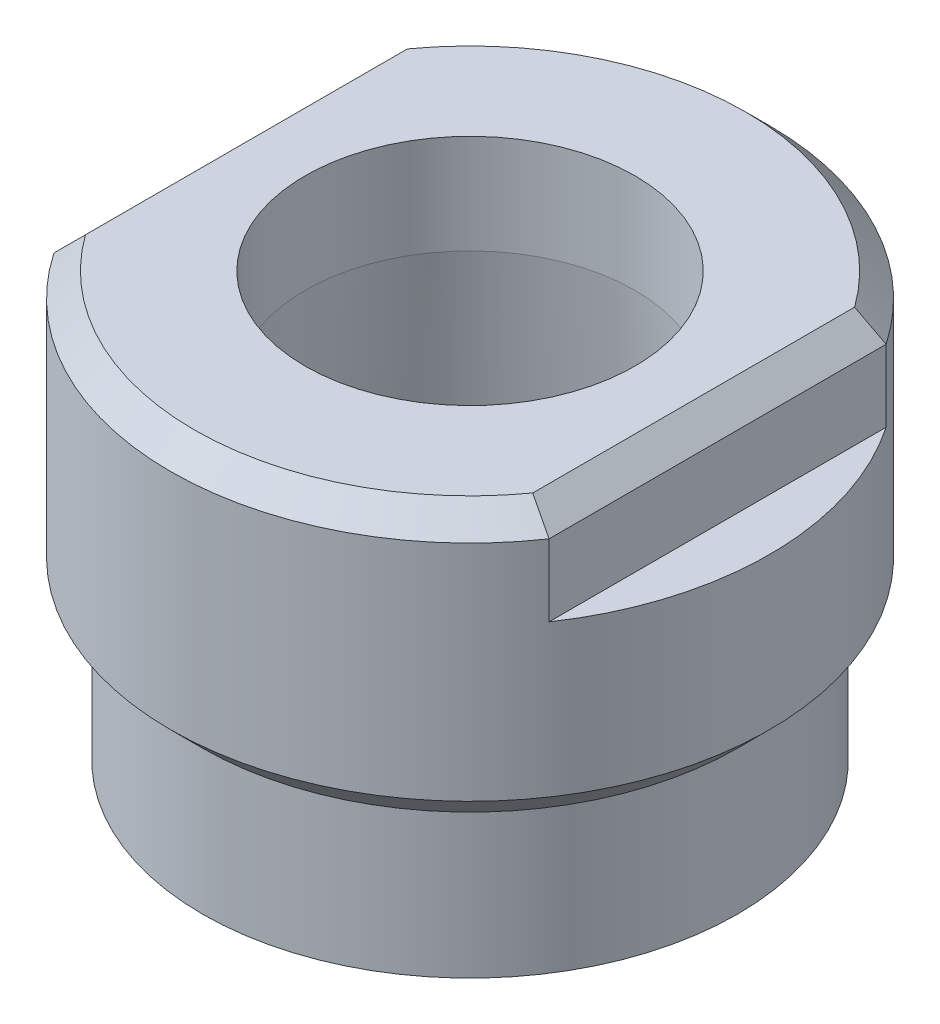
from build123d import *

# Parameters (mm, degrees)
SKETCH2_W               = 1.651
SKETCH2_H               = 3.048
CUT_EXTRUDE1_DEPTH      = 10.525
CUT_EXTRUDE1_DEPTH_BACK = 10.525
CHAMFER1_SIZE           = 0.762


with BuildPart() as part:
    # Sketch1 → Revolve1 (revolve)
    with BuildSketch(Plane.XY):
        Polygon((-5.2451, -1.885785138), (-5.969, -10.16), (-8.001, -12.192), (-8.509, -12.192), (-8.509, -7.62), (-9.525, -6.604), (-9.525, 0.508), (-8.763, 1.27), (-5.2451, 1.27), (-5.2451, 0), align=None)
    revolve(axis=Axis((0, 0, 0), (0, -1, 0)))

    # Sketch2 → Cut-Extrude1 (cut, two sides)
    with BuildSketch(Plane.XY) as cut_extrude1_sk:
        with Locations((-8.6995, -0.254)):
            Rectangle(SKETCH2_W, SKETCH2_H)
        with Locations((8.6995, -0.254)):
            Rectangle(SKETCH2_W, SKETCH2_H)
    extrude(amount=CUT_EXTRUDE1_DEPTH, mode=Mode.SUBTRACT)
    extrude(cut_extrude1_sk.sketch, amount=-CUT_EXTRUDE1_DEPTH_BACK, mode=Mode.SUBTRACT)

    # Chamfer1
    chamfer1_edges = [part.edges().sort_by_distance(p)[0] for p in [
        (7.874, 1.27, 0),
        (-7.874, 1.27, 0),
    ]]
    chamfer(chamfer1_edges, length=CHAMFER1_SIZE)


solid = part.part
